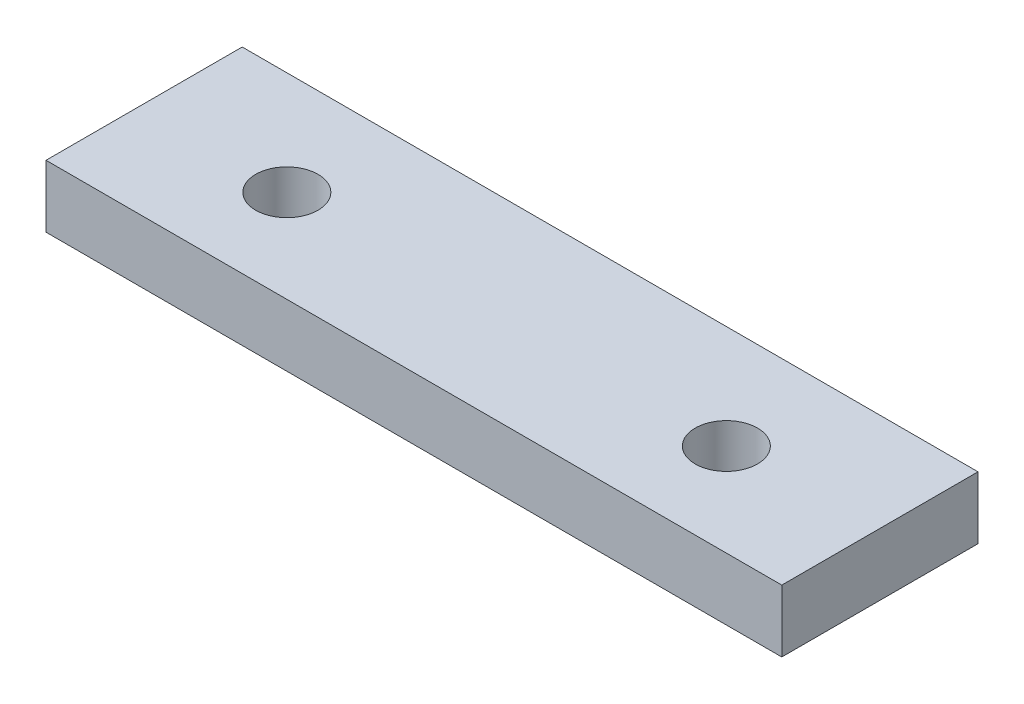
from build123d import *

# Parameters (mm, degrees)
SKETCH1_W           = 40
SKETCH1_H           = 12.7
BOSS_EXTRUDE1_DEPTH = 150
CUT_EXTRUDE1_REACH  = 14.7
SKETCH2_R           = 6.35


with BuildPart() as part:
    # Sketch1 → Boss-Extrude1 (new body)
    with BuildSketch(Plane(origin=(0, 0, 0), x_dir=(0, 0, -1), z_dir=(1, 0, 0))):
        with Locations((20, 6.35)):
            Rectangle(SKETCH1_W, SKETCH1_H)
    extrude(amount=BOSS_EXTRUDE1_DEPTH)

    # Sketch2 → Cut-Extrude1 (cut, up to next)
    with BuildSketch(Plane(origin=(0, 12.7, 0), x_dir=(1, 0, 0), z_dir=(0, 1, 0)), mode=Mode.PRIVATE) as cut_extrude1_sk1:
        with Locations((30.2, 18.9)):
            Circle(SKETCH2_R)
    cut_extrude1_tool1 = extrude(cut_extrude1_sk1.sketch, amount=-CUT_EXTRUDE1_REACH, mode=Mode.PRIVATE) & part.part
    add(cut_extrude1_tool1.solids().sort_by_distance((30.2, 12.7, -18.9))[0], mode=Mode.SUBTRACT)
    # Sketch2 → Cut-Extrude1 (cut, up to next)
    with BuildSketch(Plane(origin=(0, 12.7, 0), x_dir=(1, 0, 0), z_dir=(0, 1, 0)), mode=Mode.PRIVATE) as cut_extrude1_sk2:
        with Locations((119.8, 18.9)):
            Circle(SKETCH2_R)
    cut_extrude1_tool2 = extrude(cut_extrude1_sk2.sketch, amount=-CUT_EXTRUDE1_REACH, mode=Mode.PRIVATE) & part.part
    add(cut_extrude1_tool2.solids().sort_by_distance((119.8, 12.7, -18.9))[0], mode=Mode.SUBTRACT)


solid = part.part
